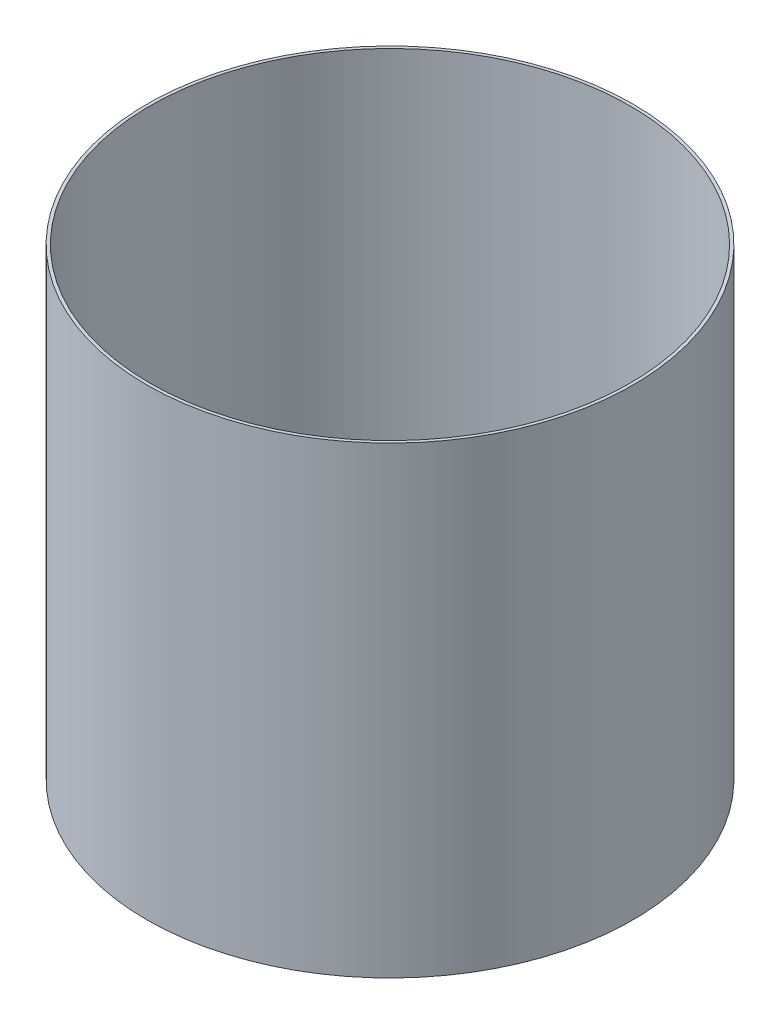
from build123d import *

# Parameters (mm, degrees)
SKETCH1_R           = 40
SKETCH1_R_2         = 39.5
BOSS_EXTRUDE1_DEPTH = 76.2


with BuildPart() as part:
    # Sketch1 → Boss-Extrude1 (new body)
    with BuildSketch(Plane(origin=(0, 0, 0), x_dir=(1, 0, 0), z_dir=(0, 1, 0))):
        Circle(SKETCH1_R)
        Circle(SKETCH1_R_2, mode=Mode.SUBTRACT)
    extrude(amount=BOSS_EXTRUDE1_DEPTH)


solid = part.part
